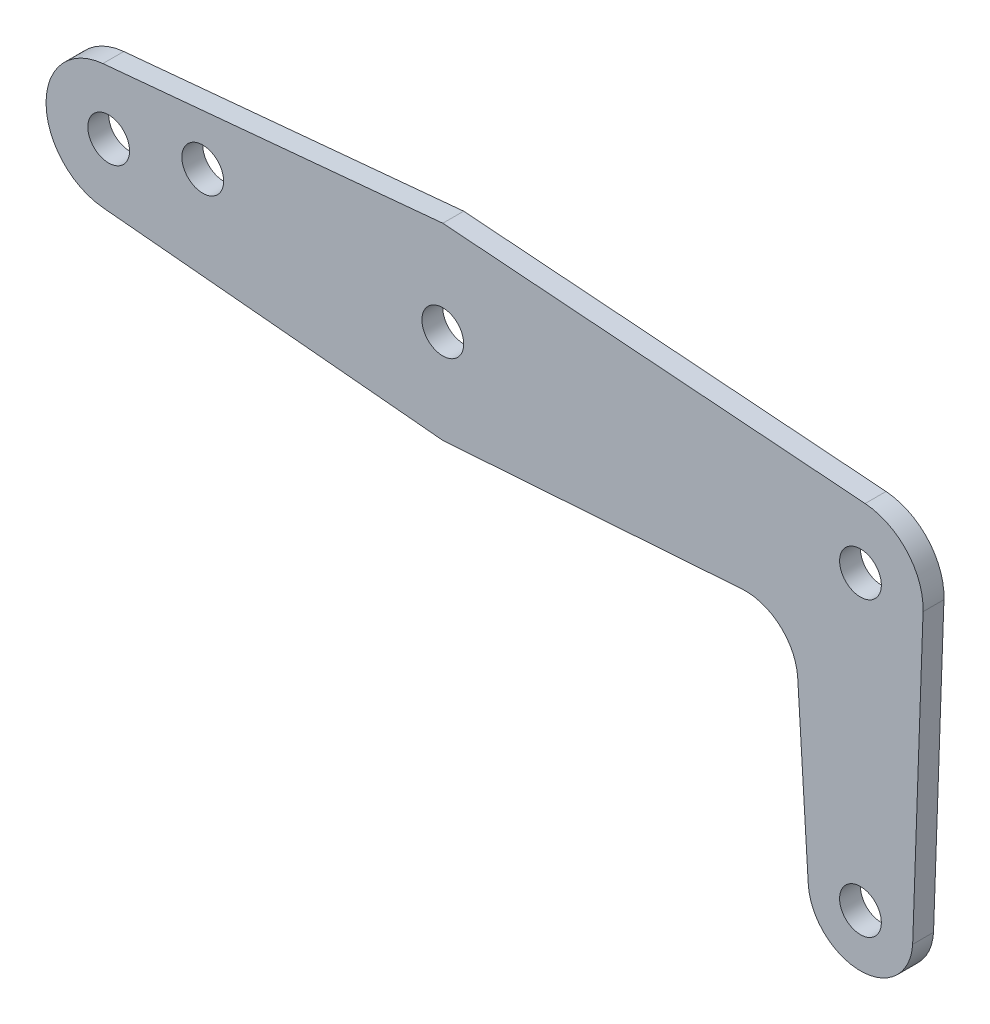
from build123d import *

# Parameters (mm, degrees)
SKETCH2_R           = 1.25
BOSS_EXTRUDE1_DEPTH = 1.25


with BuildPart() as part:
    # Sketch2 → Boss-Extrude1 (new body)
    with BuildSketch(Plane.XY):
        with BuildLine():
            Line((0.279648542, 3.739558355), (-25, 5.63))
            Line((-25, 5.63), (-45.347946147, 3.733822904))
            ThreePointArc((-45.347946147, 3.733822904), (-48.75, 0), (-45.347946147, -3.733822904))
            Line((-45.347946147, -3.733822904), (-25, -5.63))
            Line((-25, -5.63), (-7.098436577, -4.377631434))
            ThreePointArc((-7.098436577, -4.377631434), (-4.815909482, -5.147037966), (-3.75577728, -7.309914769))
            Line((-3.75577728, -7.309914769), (-3.12422272, -17.690085231))
            ThreePointArc((-3.12422272, -17.690085231), (0, -20.63), (3.12422272, -17.690085231))
            Line((3.12422272, -17.690085231), (3.747638192, -0.133071355))
            ThreePointArc((3.747638192, -0.133071355), (2.793577424, 2.501684467), (0.279648542, 3.739558355))
        make_face()
        Circle(SKETCH2_R, mode=Mode.SUBTRACT)
        with Locations((0, -17.5)):
            Circle(SKETCH2_R, mode=Mode.SUBTRACT)
        with Locations((-45, 0)):
            Circle(SKETCH2_R, mode=Mode.SUBTRACT)
        with Locations((-25, 0)):
            Circle(SKETCH2_R, mode=Mode.SUBTRACT)
        with Locations((-39.37, 1.25)):
            Circle(SKETCH2_R, mode=Mode.SUBTRACT)
    extrude(amount=BOSS_EXTRUDE1_DEPTH)


solid = part.part
